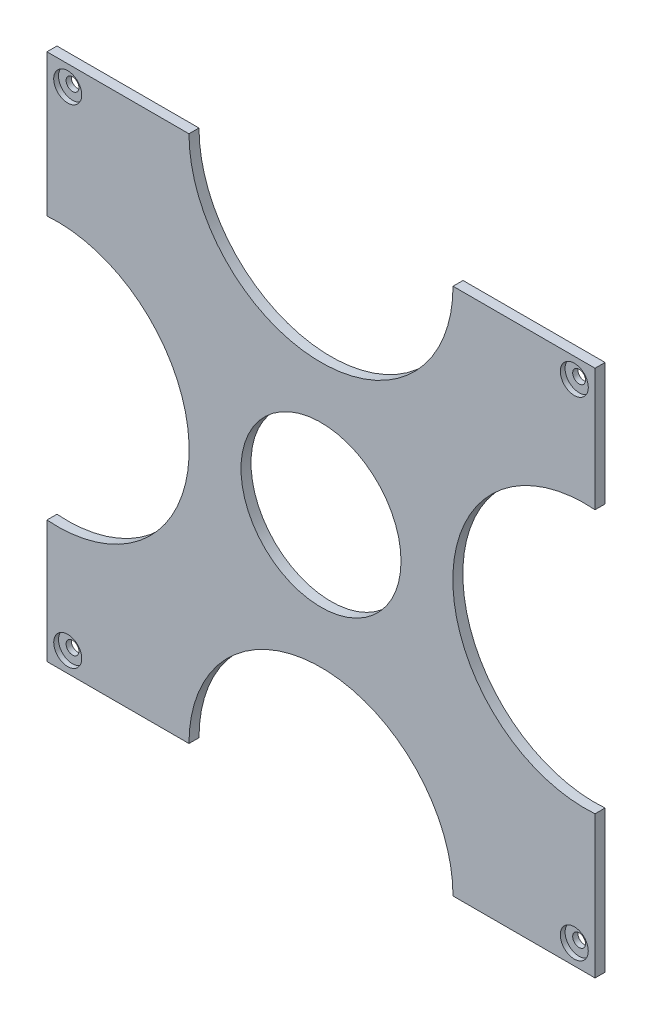
from build123d import *

# Parameters (mm, degrees)
SKETCH_1_R          = 1.6
EXTRUDE_1_DEPTH     = 2.5
SKETCH_2_R          = 20
CUT_EXTRUDE_1_DEPTH = 23
SKETCH_3_R          = 3.5
CUT_EXTRUDE_2_DEPTH = 1.2


with BuildPart() as part:
    # 草图1 → 凸台-拉伸1 (new body)
    with BuildSketch(Plane.XY):
        with BuildLine():
            Line((68.5, 66), (33, 66))
            ThreePointArc((33, 66), (0, 33), (-33, 66))
            Line((-33, 66), (-68.5, 66))
            Line((-68.5, 66), (-68.5, 30.44898712))
            ThreePointArc((-68.5, 30.44898712), (-43.537948759, 21.765123634), (-32.954411074, -2.452684221))
            ThreePointArc((-32.954411074, -2.452684221), (-43.537948759, -26.670492075), (-68.5, -35.354355562))
            Line((-68.5, -35.354355562), (-68.5, -66))
            Line((-68.5, -66), (-33, -66))
            ThreePointArc((-33, -66), (0, -33), (33, -66))
            Line((33, -66), (68.5, -66))
            Line((68.5, -66), (68.5, -30.44898712))
            ThreePointArc((68.5, -30.44898712), (32.954411074, 2.452684221), (68.5, 35.354355562))
            Line((68.5, 35.354355562), (68.5, 66))
        make_face()
        with Locations((-63.310606061, -61)):
            Circle(SKETCH_1_R, mode=Mode.SUBTRACT)
        with Locations((63.310606061, -61)):
            Circle(SKETCH_1_R, mode=Mode.SUBTRACT)
        with Locations((-63.310606061, 61)):
            Circle(SKETCH_1_R, mode=Mode.SUBTRACT)
        with Locations((63.310606061, 61)):
            Circle(SKETCH_1_R, mode=Mode.SUBTRACT)
    extrude(amount=EXTRUDE_1_DEPTH)

    # 草图2 → 切除-拉伸1 (cut)
    with BuildSketch(Plane.XY.offset(2.5)):
        Circle(SKETCH_2_R)
    extrude(amount=-CUT_EXTRUDE_1_DEPTH, mode=Mode.SUBTRACT)

    # 草图3 → 切除-拉伸2 (cut)
    with BuildSketch(Plane.XY.offset(2.5)):
        with Locations((63.310606061, -61)):
            Circle(SKETCH_3_R)
        with Locations((63.310606061, 61)):
            Circle(SKETCH_3_R)
        with Locations((-63.310606061, 61)):
            Circle(SKETCH_3_R)
        with Locations((-63.310606061, -61)):
            Circle(SKETCH_3_R)
    extrude(amount=-CUT_EXTRUDE_2_DEPTH, mode=Mode.SUBTRACT)


solid = part.part
